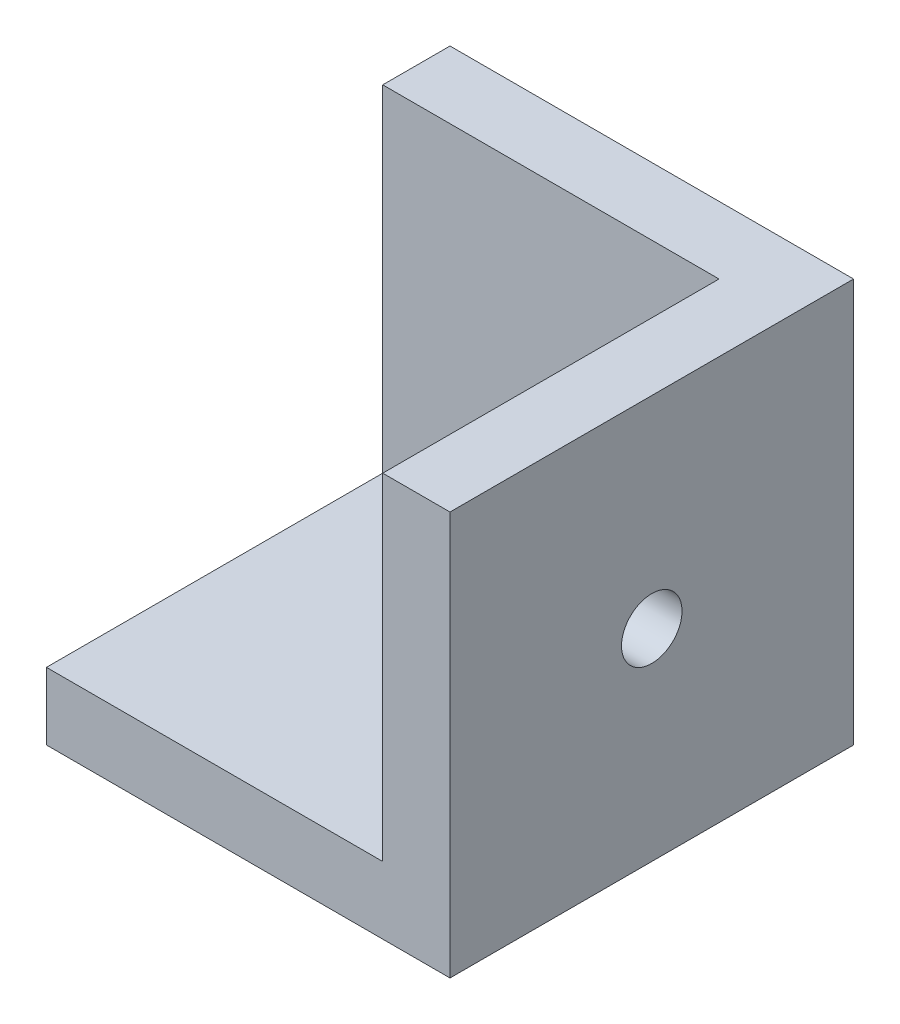
from build123d import *

# Parameters (mm, degrees)
ESBO_O1_W                         = 30
ESBO_O1_H                         = 30
RESSALTO_EXTRUS_O1_DEPTH          = 30
ESBO_O3_W                         = 25
ESBO_O3_H                         = 25
CORTE_EXTRUS_O2_DEPTH             = 25
FURO_COM_FOLGA_DE_M41_D           = 4.5
FURO_COM_FOLGA_DE_M41_ON_FACE_2_D = 4.5
FURO_COM_FOLGA_DE_M31_D           = 3.4


with BuildPart() as part:
    # Esboço1 → Ressalto-extrusão1 (new body)
    with BuildSketch(Plane.XY):
        with Locations((-15, 15)):
            Rectangle(ESBO_O1_W, ESBO_O1_H)
    extrude(amount=RESSALTO_EXTRUS_O1_DEPTH)

    # Esboço3 → Corte-extrusão2 (cut)
    with BuildSketch(Plane(origin=(0, 30, 0), x_dir=(1, 0, 0), z_dir=(0, 1, 0))):
        with Locations((-17.5, -17.5)):
            Rectangle(ESBO_O3_W, ESBO_O3_H)
    extrude(amount=-CORTE_EXTRUS_O2_DEPTH, mode=Mode.SUBTRACT)

    # Furo com folga de M41 (through all)
    with Locations(Plane(origin=(-5, 15, 15), x_dir=(0, 0, -1), z_dir=(-1, 0, 0))):
        with Locations((0, 0)):
            Hole(FURO_COM_FOLGA_DE_M41_D / 2)

    # Furo com folga de M41 on face 2 (through all)
    with Locations(Plane(origin=(-15, 5, 15), x_dir=(0, 0, 1), z_dir=(0, 1, 0))):
        with Locations((0, 0)):
            Hole(FURO_COM_FOLGA_DE_M41_ON_FACE_2_D / 2)

    # Furo com folga de M31 (through all)
    with Locations(Plane(origin=(-11, 15, 0), x_dir=(-1, 0, 0), z_dir=(0, 0, -1))):
        with Locations((0, 0)):
            Hole(FURO_COM_FOLGA_DE_M31_D / 2)


solid = part.part
